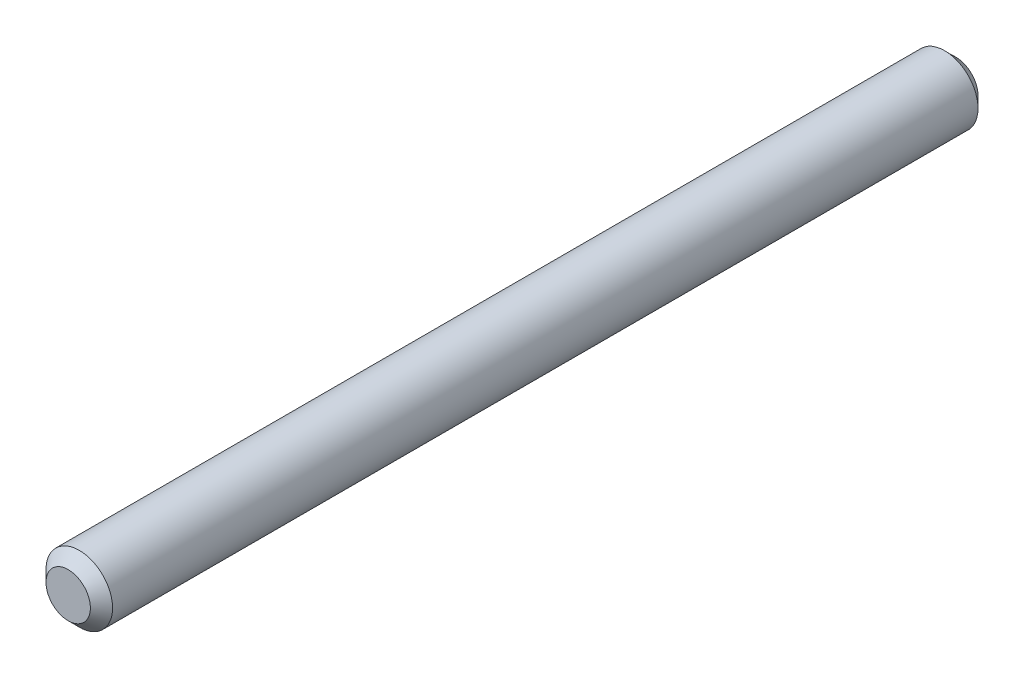
from build123d import *

# Parameters (mm, degrees)
SKETCH1_R     = 1.5
BODY_DEPTH    = 20
CHAMFER1_SIZE = 0.5


with BuildPart() as part:
    # Sketch1 → Body (new body, symmetric)
    with BuildSketch(Plane.XY):
        Circle(SKETCH1_R)
    extrude(amount=BODY_DEPTH, both=True)

    # Chamfer1
    chamfer1_edges = [part.edges().sort_by_distance(p)[0] for p in [
        (-1.5, 0, -20),
        (-1.5, 0, 20),
    ]]
    chamfer(chamfer1_edges, length=CHAMFER1_SIZE)


solid = part.part
